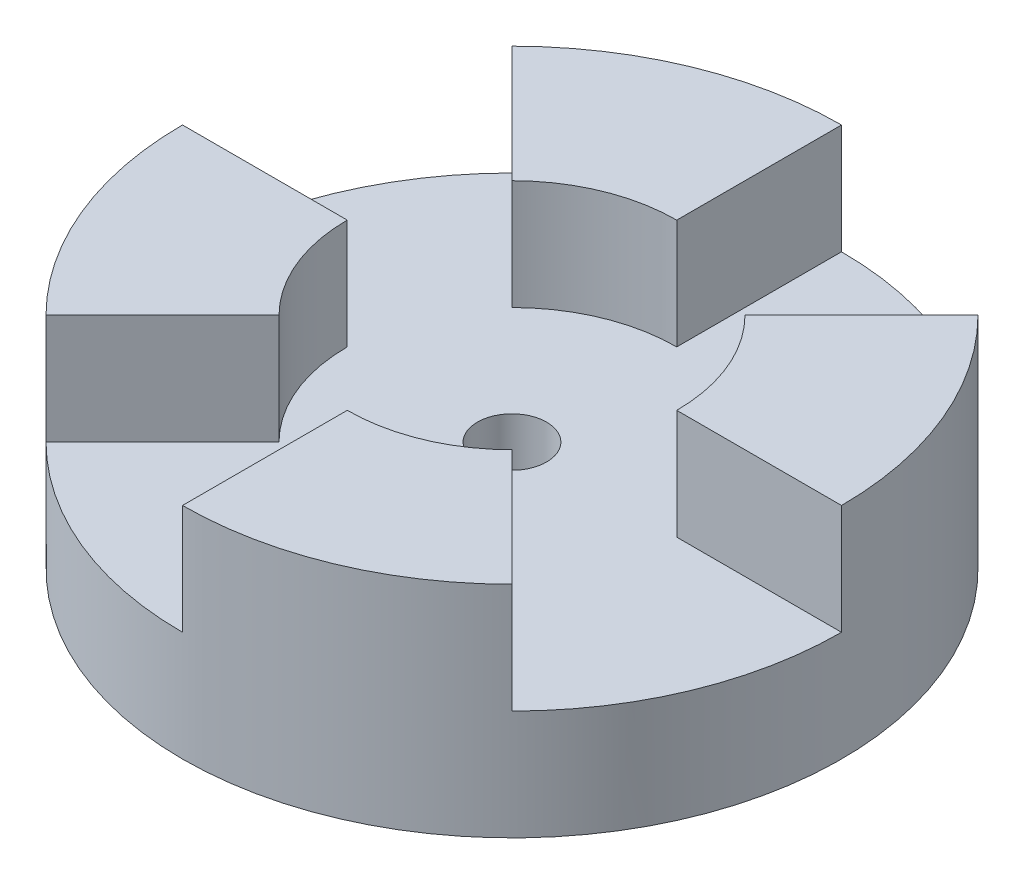
from build123d import *

# Parameters (mm, degrees)
SKETCH1_R           = 38.1
BOSS_EXTRUDE1_DEPTH = 12.7
SKETCH2_R           = 4.0005
CUT_EXTRUDE1_DEPTH  = 12.7
BOSS_EXTRUDE2_DEPTH = 12.7
SKETCH5_R           = 5.334
CUT_EXTRUDE2_DEPTH  = 2.54


with BuildPart() as part:
    # Sketch1 → Boss-Extrude1 (new body)
    with BuildSketch(Plane(origin=(0, 0, 0), x_dir=(1, 0, 0), z_dir=(0, 1, 0))):
        with Locations((-80.789858777, -8.415610289)):
            Circle(SKETCH1_R)
    extrude(amount=BOSS_EXTRUDE1_DEPTH)

    # Sketch2 → Cut-Extrude1 (cut)
    with BuildSketch(Plane(origin=(0, 12.7, 0), x_dir=(1, 0, 0), z_dir=(0, 1, 0))):
        with Locations((-80.789858777, -8.415610289)):
            Circle(SKETCH2_R)
    extrude(amount=-CUT_EXTRUDE1_DEPTH, mode=Mode.SUBTRACT)

    # Sketch3 → Boss-Extrude2 (add)
    with BuildSketch(Plane(origin=(0, 12.7, 0), x_dir=(1, 0, 0), z_dir=(0, 1, 0))):
        with BuildLine():
            ThreePointArc((-94.260242958, 5.054773892), (-88.079978163, 9.184294805), (-80.789858777, 10.634389711))
            Line((-80.789858777, 10.634389711), (-80.789858777, 29.684389711))
            ThreePointArc((-80.789858777, 29.684389711), (-95.37009755, 26.784199899), (-107.73062714, 18.525158074))
            Line((-107.73062714, 18.525158074), (-94.260242958, 5.054773892))
        make_face()
        with BuildLine():
            Line((-53.849090413, 18.525158074), (-67.319474595, 5.054773892))
            ThreePointArc((-67.319474595, 5.054773892), (-63.189953682, -1.125490903), (-61.739858777, -8.415610289))
            Line((-61.739858777, -8.415610289), (-42.689858777, -8.415610289))
            ThreePointArc((-42.689858777, -8.415610289), (-45.590048588, 6.164628484), (-53.849090413, 18.525158074))
        make_face()
        with BuildLine():
            Line((-53.849090413, -35.356378652), (-67.319474595, -21.885994471))
            ThreePointArc((-67.319474595, -21.885994471), (-73.49973939, -26.015515384), (-80.789858777, -27.465610289))
            Line((-80.789858777, -27.465610289), (-80.789858777, -46.515610289))
            ThreePointArc((-80.789858777, -46.515610289), (-66.209620003, -43.615420478), (-53.849090413, -35.356378652))
        make_face()
        with BuildLine():
            ThreePointArc((-94.260242958, -21.885994471), (-98.389763871, -15.705729676), (-99.839858777, -8.415610289))
            Line((-99.839858777, -8.415610289), (-118.889858777, -8.415610289))
            ThreePointArc((-118.889858777, -8.415610289), (-115.989668965, -22.995849062), (-107.73062714, -35.356378652))
            Line((-107.73062714, -35.356378652), (-94.260242958, -21.885994471))
        make_face()
    extrude(amount=BOSS_EXTRUDE2_DEPTH)

    # Sketch5 → Cut-Extrude2 (cut)
    with BuildSketch(Plane.XZ):
        with Locations((-80.789858777, 8.415610289)):
            Circle(SKETCH5_R)
    extrude(amount=-CUT_EXTRUDE2_DEPTH, mode=Mode.SUBTRACT)


solid = part.part
